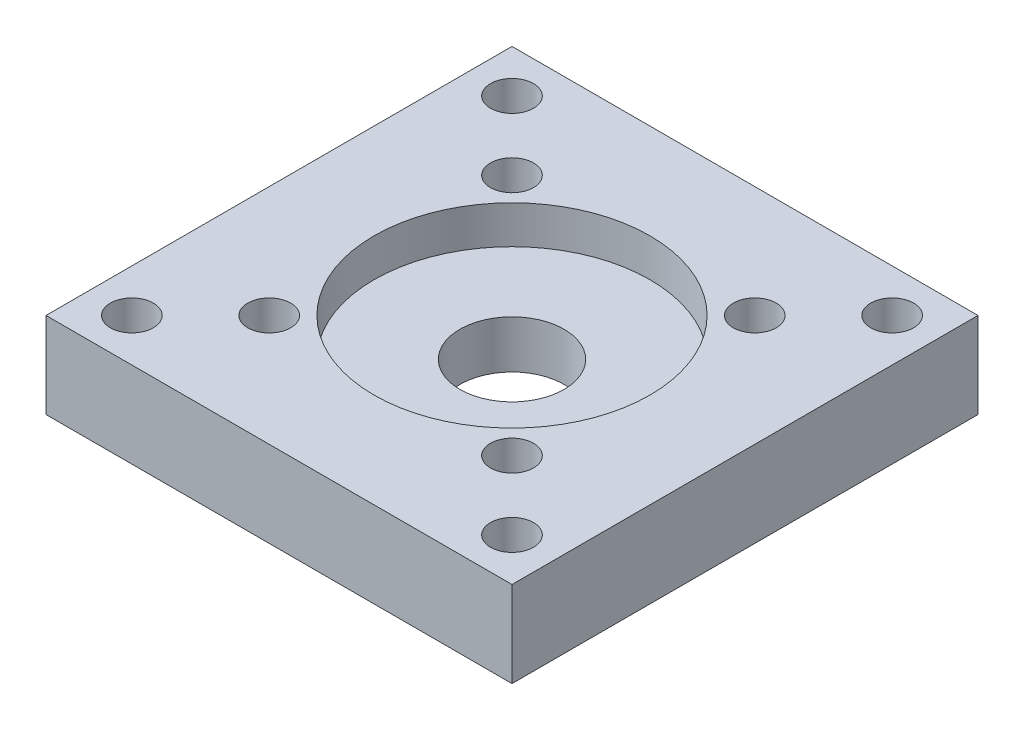
from build123d import *

# Parameters (mm, degrees)
SKETCH1_W           = 38
SKETCH1_H           = 38
BOSS_EXTRUDE1_DEPTH = 7
SKETCH2_R           = 4.25
CUT_EXTRUDE1_DEPTH  = 7
SKETCH3_R           = 11.25
CUT_EXTRUDE2_DEPTH  = 3.1
SKETCH5_R           = 1.75
CUT_EXTRUDE3_DEPTH  = 27
SKETCH6_R           = 2.75
SKETCH6_R_2         = 1.75
CUT_EXTRUDE14_DEPTH = 3.5


with BuildPart() as part:
    # Sketch1 → Boss-Extrude1 (new body)
    with BuildSketch(Plane(origin=(0, 0, 0), x_dir=(1, 0, 0), z_dir=(0, 1, 0))):
        Rectangle(SKETCH1_W, SKETCH1_H)
    extrude(amount=BOSS_EXTRUDE1_DEPTH)

    # Sketch2 → Cut-Extrude1 (cut)
    with BuildSketch(Plane(origin=(0, 7, 0), x_dir=(1, 0, 0), z_dir=(0, 1, 0))):
        with BuildLine():
            ThreePointArc((-13.75, 15.5), (-16.737436867, 16.737436867), (-15.5, 13.75))
            Line((-15.5, 13.75), (-15.5, 15.5))
            Line((-15.5, 15.5), (-13.75, 15.5))
        make_face()
        with BuildLine():
            Line((-15.5, 15.5), (-15.5, 13.75))
            ThreePointArc((-15.5, 13.75), (-14.262563133, 14.262563133), (-13.75, 15.5))
            Line((-13.75, 15.5), (-15.5, 15.5))
        make_face()
        with BuildLine():
            ThreePointArc((13.75, 15.5), (14.262563133, 14.262563133), (15.5, 13.75))
            Line((15.5, 13.75), (15.5, 15.5))
            Line((15.5, 15.5), (13.75, 15.5))
        make_face()
        with BuildLine():
            Line((15.5, 15.5), (15.5, 13.75))
            ThreePointArc((15.5, 13.75), (16.737436867, 14.262563133), (17.25, 15.5))
            ThreePointArc((17.25, 15.5), (15.5, 17.25), (13.75, 15.5))
            Line((13.75, 15.5), (15.5, 15.5))
        make_face()
        with BuildLine():
            ThreePointArc((15.5, -13.75), (14.262563133, -14.262563133), (13.75, -15.5))
            Line((13.75, -15.5), (15.5, -15.5))
            Line((15.5, -15.5), (15.5, -13.75))
        make_face()
        with BuildLine():
            Line((15.5, -15.5), (13.75, -15.5))
            ThreePointArc((13.75, -15.5), (15.5, -17.25), (17.25, -15.5))
            ThreePointArc((17.25, -15.5), (16.737436867, -14.262563133), (15.5, -13.75))
            Line((15.5, -13.75), (15.5, -15.5))
        make_face()
        with BuildLine():
            ThreePointArc((-15.5, -13.75), (-16.737436867, -16.737436867), (-13.75, -15.5))
            Line((-13.75, -15.5), (-15.5, -15.5))
            Line((-15.5, -15.5), (-15.5, -13.75))
        make_face()
        with BuildLine():
            Line((-15.5, -15.5), (-13.75, -15.5))
            ThreePointArc((-13.75, -15.5), (-14.262563133, -14.262563133), (-15.5, -13.75))
            Line((-15.5, -13.75), (-15.5, -15.5))
        make_face()
        Circle(SKETCH2_R)
    extrude(amount=-CUT_EXTRUDE1_DEPTH, mode=Mode.SUBTRACT)

    # Sketch3 → Cut-Extrude2 (cut)
    with BuildSketch(Plane(origin=(0, 7, 0), x_dir=(1, 0, 0), z_dir=(0, 1, 0))):
        Circle(SKETCH3_R)
    extrude(amount=-CUT_EXTRUDE2_DEPTH, mode=Mode.SUBTRACT)

    # Sketch5 → Cut-Extrude3 (cut)
    with BuildSketch(Plane(origin=(0, 7, 0), x_dir=(1, 0, 0), z_dir=(0, 1, 0))):
        with Locations((-9.899494937, 9.899494937)):
            Circle(SKETCH5_R)
        with Locations((9.899494937, 9.899494937)):
            Circle(SKETCH5_R)
        with Locations((9.899494937, -9.899494937)):
            Circle(SKETCH5_R)
        with Locations((-9.899494937, -9.899494937)):
            Circle(SKETCH5_R)
    extrude(amount=-CUT_EXTRUDE3_DEPTH, mode=Mode.SUBTRACT)

    # Sketch6 → Cut-Extrude14 (cut)
    with BuildSketch(Plane.XZ):
        with Locations((-9.899494937, 9.899494937)):
            Circle(SKETCH6_R)
        with Locations((-9.899494937, 9.899494937)):
            Circle(SKETCH6_R_2, mode=Mode.SUBTRACT)
        with Locations((9.899494937, 9.899494937)):
            Circle(SKETCH6_R)
        with Locations((9.899494937, 9.899494937)):
            Circle(SKETCH6_R_2, mode=Mode.SUBTRACT)
        with Locations((9.899494937, -9.899494937)):
            Circle(SKETCH6_R)
        with Locations((9.899494937, -9.899494937)):
            Circle(SKETCH6_R_2, mode=Mode.SUBTRACT)
        with Locations((-9.899494937, -9.899494937)):
            Circle(SKETCH6_R)
        with Locations((-9.899494937, -9.899494937)):
            Circle(SKETCH6_R_2, mode=Mode.SUBTRACT)
    extrude(amount=-CUT_EXTRUDE14_DEPTH, mode=Mode.SUBTRACT)


solid = part.part
